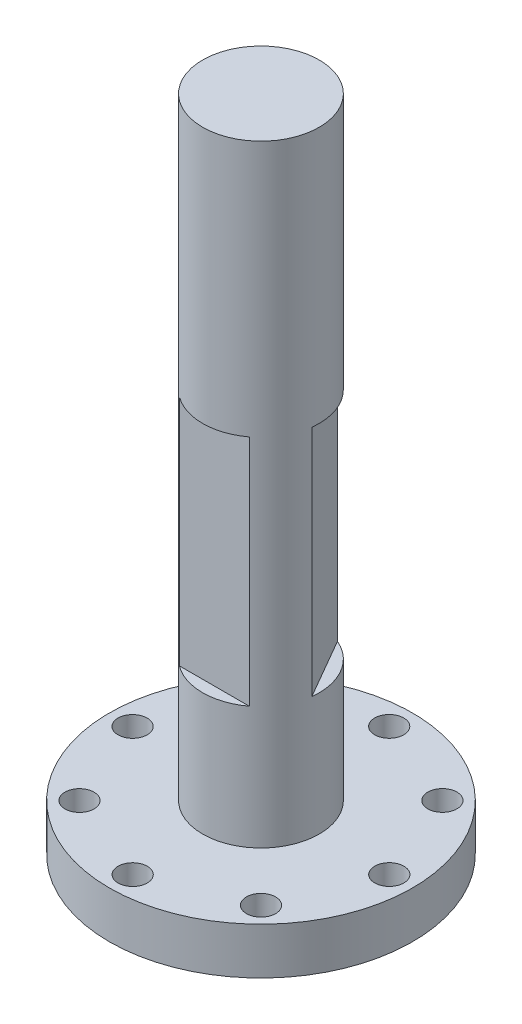
from build123d import *

# Parameters (mm, degrees)
SKETCH_1_R          = 13
EXTRUDE_1_DEPTH     = 4
SKETCH_2_R          = 5
EXTRUDE_2_DEPTH     = 52.5
CUT_EXTRUDE_1_REACH = 6
SKETCH_3_R          = 1.25
SKETCH_4_W          = 6
SKETCH_4_H          = 20
CUT_EXTRUDE_2_DEPTH = 1
SKETCH_5_W          = 20
SKETCH_5_H          = 6
CUT_EXTRUDE_3_DEPTH = 1
SKETCH_6_R          = 6
CUT_EXTRUDE_5_DEPTH = 3
SKETCH_7_R          = 3
CUT_EXTRUDE_6_DEPTH = 5


with BuildPart() as part:
    # 스케치1 → 보스-돌출1 (new body)
    with BuildSketch(Plane(origin=(0, 0, 0), x_dir=(1, 0, 0), z_dir=(0, 1, 0))):
        Circle(SKETCH_1_R)
    extrude(amount=EXTRUDE_1_DEPTH)

    # 스케치2 → 보스-돌출2 (add)
    with BuildSketch(Plane(origin=(0, 4, 0), x_dir=(1, 0, 0), z_dir=(0, 1, 0))):
        Circle(SKETCH_2_R)
    extrude(amount=EXTRUDE_2_DEPTH)

    # 스케치3 → 컷-돌출1 (cut, up to next)
    with BuildSketch(Plane(origin=(0, 4, 0), x_dir=(1, 0, 0), z_dir=(0, 1, 0)), mode=Mode.PRIVATE) as cut_extrude_1_sk1:
        with Locations((0, 11)):
            Circle(SKETCH_3_R)
    cut_extrude_1_tool1 = extrude(cut_extrude_1_sk1.sketch, amount=-CUT_EXTRUDE_1_REACH, mode=Mode.PRIVATE) & part.part
    add(cut_extrude_1_tool1.solids().sort_by_distance((0, 4, -11))[0], mode=Mode.SUBTRACT)
    # 스케치3 → 컷-돌출1 (cut, up to next)
    with BuildSketch(Plane(origin=(0, 4, 0), x_dir=(1, 0, 0), z_dir=(0, 1, 0)), mode=Mode.PRIVATE) as cut_extrude_1_sk2:
        with Locations((7.781876099, 7.779707807)):
            Circle(SKETCH_3_R)
    cut_extrude_1_tool2 = extrude(cut_extrude_1_sk2.sketch, amount=-CUT_EXTRUDE_1_REACH, mode=Mode.PRIVATE) & part.part
    add(cut_extrude_1_tool2.solids().sort_by_distance((7.781876, 4, -7.779708))[0], mode=Mode.SUBTRACT)
    # 스케치3 → 컷-돌출1 (cut, up to next)
    with BuildSketch(Plane(origin=(0, 4, 0), x_dir=(1, 0, 0), z_dir=(0, 1, 0)), mode=Mode.PRIVATE) as cut_extrude_1_sk3:
        with Locations((11.007403012, 0)):
            Circle(SKETCH_3_R)
    cut_extrude_1_tool3 = extrude(cut_extrude_1_sk3.sketch, amount=-CUT_EXTRUDE_1_REACH, mode=Mode.PRIVATE) & part.part
    add(cut_extrude_1_tool3.solids().sort_by_distance((11.007403, 4, 0))[0], mode=Mode.SUBTRACT)
    # 스케치3 → 컷-돌출1 (cut, up to next)
    with BuildSketch(Plane(origin=(0, 4, 0), x_dir=(1, 0, 0), z_dir=(0, 1, 0)), mode=Mode.PRIVATE) as cut_extrude_1_sk4:
        with Locations((7.787110819, -7.781876099)):
            Circle(SKETCH_3_R)
    cut_extrude_1_tool4 = extrude(cut_extrude_1_sk4.sketch, amount=-CUT_EXTRUDE_1_REACH, mode=Mode.PRIVATE) & part.part
    add(cut_extrude_1_tool4.solids().sort_by_distance((7.787111, 4, 7.781876))[0], mode=Mode.SUBTRACT)
    # 스케치3 → 컷-돌출1 (cut, up to next)
    with BuildSketch(Plane(origin=(0, 4, 0), x_dir=(1, 0, 0), z_dir=(0, 1, 0)), mode=Mode.PRIVATE) as cut_extrude_1_sk5:
        with Locations((0.007403012, -11.007403012)):
            Circle(SKETCH_3_R)
    cut_extrude_1_tool5 = extrude(cut_extrude_1_sk5.sketch, amount=-CUT_EXTRUDE_1_REACH, mode=Mode.PRIVATE) & part.part
    add(cut_extrude_1_tool5.solids().sort_by_distance((0.007403, 4, 11.007403))[0], mode=Mode.SUBTRACT)
    # 스케치3 → 컷-돌출1 (cut, up to next)
    with BuildSketch(Plane(origin=(0, 4, 0), x_dir=(1, 0, 0), z_dir=(0, 1, 0)), mode=Mode.PRIVATE) as cut_extrude_1_sk6:
        with Locations((-7.774473087, -7.787110819)):
            Circle(SKETCH_3_R)
    cut_extrude_1_tool6 = extrude(cut_extrude_1_sk6.sketch, amount=-CUT_EXTRUDE_1_REACH, mode=Mode.PRIVATE) & part.part
    add(cut_extrude_1_tool6.solids().sort_by_distance((-7.774473, 4, 7.787111))[0], mode=Mode.SUBTRACT)
    # 스케치3 → 컷-돌출1 (cut, up to next)
    with BuildSketch(Plane(origin=(0, 4, 0), x_dir=(1, 0, 0), z_dir=(0, 1, 0)), mode=Mode.PRIVATE) as cut_extrude_1_sk7:
        with Locations((-11, -0.007403012)):
            Circle(SKETCH_3_R)
    cut_extrude_1_tool7 = extrude(cut_extrude_1_sk7.sketch, amount=-CUT_EXTRUDE_1_REACH, mode=Mode.PRIVATE) & part.part
    add(cut_extrude_1_tool7.solids().sort_by_distance((-11, 4, 0.007403))[0], mode=Mode.SUBTRACT)
    # 스케치3 → 컷-돌출1 (cut, up to next)
    with BuildSketch(Plane(origin=(0, 4, 0), x_dir=(1, 0, 0), z_dir=(0, 1, 0)), mode=Mode.PRIVATE) as cut_extrude_1_sk8:
        with Locations((-7.779707807, 7.774473087)):
            Circle(SKETCH_3_R)
    cut_extrude_1_tool8 = extrude(cut_extrude_1_sk8.sketch, amount=-CUT_EXTRUDE_1_REACH, mode=Mode.PRIVATE) & part.part
    add(cut_extrude_1_tool8.solids().sort_by_distance((-7.779708, 4, -7.774473))[0], mode=Mode.SUBTRACT)

    # 스케치4 → 컷-돌출2 (cut)
    with BuildSketch(Plane.XY.offset(5)):
        with Locations((0, 24.5)):
            Rectangle(SKETCH_4_W, SKETCH_4_H)
    extrude(amount=-CUT_EXTRUDE_2_DEPTH, mode=Mode.SUBTRACT)

    # 스케치5 → 컷-돌출3 (cut)
    with BuildSketch(Plane(origin=(4.330127019, 0, -2.5), x_dir=(0, -1, 0), z_dir=(0.866025404, 0, -0.5))):
        with Locations((-24.5, 0)):
            Rectangle(SKETCH_5_W, SKETCH_5_H)
    extrude(amount=-CUT_EXTRUDE_3_DEPTH, mode=Mode.SUBTRACT)

    # 스케치6 → 컷-돌출5 (cut)
    with BuildSketch(Plane.XZ):
        Circle(SKETCH_6_R)
    extrude(amount=-CUT_EXTRUDE_5_DEPTH, mode=Mode.SUBTRACT)

    # 스케치7 → 컷-돌출6 (cut)
    with BuildSketch(Plane.XZ.offset(-3)):
        Circle(SKETCH_7_R)
    extrude(amount=-CUT_EXTRUDE_6_DEPTH, mode=Mode.SUBTRACT)


solid = part.part
